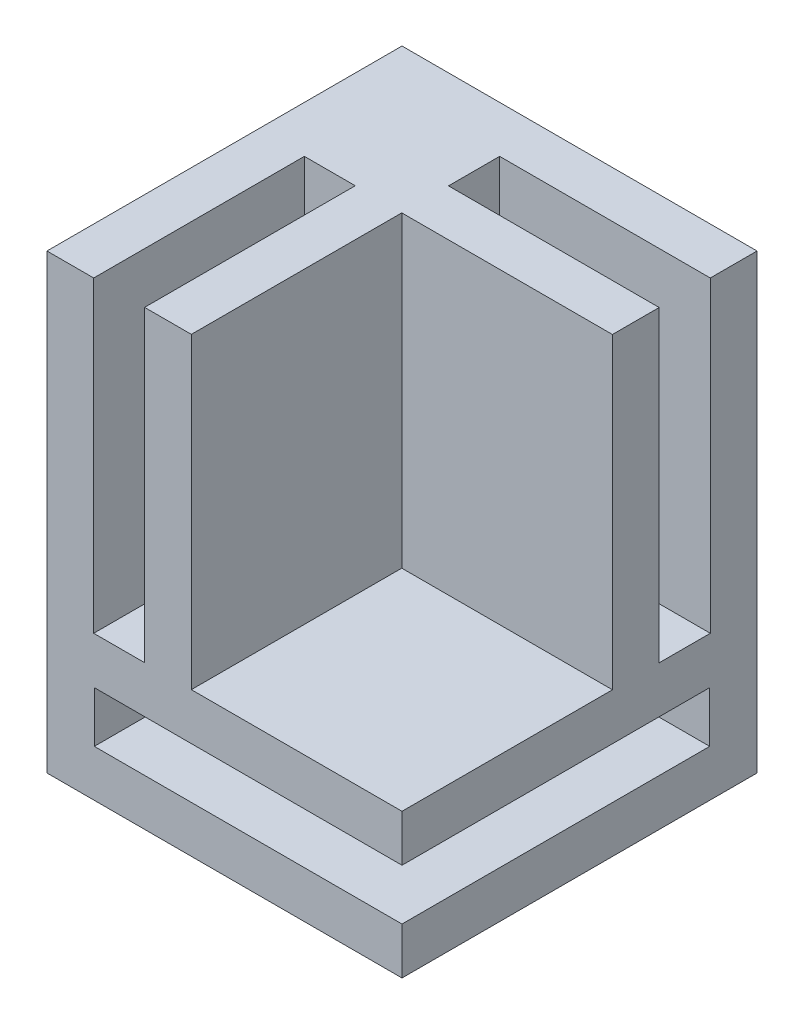
from build123d import *

# Parameters (mm, degrees)
SKETCH1_W           = 30
SKETCH1_H           = 12.2
BOSS_EXTRUDE1_DEPTH = 30
SKETCH2_W           = 26
SKETCH2_H           = 4.3
CUT_EXTRUDE1_DEPTH  = 26
SKETCH3_W           = 30
SKETCH3_H           = 30
BOSS_EXTRUDE2_DEPTH = 26
SKETCH4_W           = 17.8
SKETCH4_H           = 17.78
CUT_EXTRUDE2_DEPTH  = 26
SKETCH6_W           = 4.32
SKETCH6_H           = 26
CUT_EXTRUDE3_DEPTH  = 17.8
SKETCH9_W           = 4.3
SKETCH9_H           = 26
CUT_EXTRUDE4_DEPTH  = 17.8


with BuildPart() as part:
    # Sketch1 → Boss-Extrude1 (new body)
    with BuildSketch(Plane.XY):
        with Locations((-26.249929658, 18.197752809)):
            Rectangle(SKETCH1_W, SKETCH1_H)
    extrude(amount=BOSS_EXTRUDE1_DEPTH)

    # Sketch2 → Cut-Extrude1 (cut)
    with BuildSketch(Plane(origin=(-11.249929658, 0, 0), x_dir=(0, 0, -1), z_dir=(1, 0, 0))):
        with Locations((-17, 18.197752809)):
            Rectangle(SKETCH2_W, SKETCH2_H)
    extrude(amount=-CUT_EXTRUDE1_DEPTH, mode=Mode.SUBTRACT)

    # Sketch3 → Boss-Extrude2 (add)
    with BuildSketch(Plane(origin=(0, 24.297752809, 0), x_dir=(1, 0, 0), z_dir=(0, 1, 0))):
        with Locations((-26.249929658, -15)):
            Rectangle(SKETCH3_W, SKETCH3_H)
    extrude(amount=BOSS_EXTRUDE2_DEPTH)

    # Sketch4 → Cut-Extrude2 (cut)
    with BuildSketch(Plane(origin=(0, 50.297752809, 0), x_dir=(1, 0, 0), z_dir=(0, 1, 0))):
        with Locations((-20.149929658, -21.11)):
            Rectangle(SKETCH4_W, SKETCH4_H)
    extrude(amount=-CUT_EXTRUDE2_DEPTH, mode=Mode.SUBTRACT)

    # Sketch6 → Cut-Extrude3 (cut)
    with BuildSketch(Plane(origin=(-11.249929658, 0, 0), x_dir=(0, 0, -1), z_dir=(1, 0, 0))):
        with Locations((-6.11, 37.297752809)):
            Rectangle(SKETCH6_W, SKETCH6_H)
    extrude(amount=-CUT_EXTRUDE3_DEPTH, mode=Mode.SUBTRACT)

    # Sketch9 → Cut-Extrude4 (cut)
    with BuildSketch(Plane.XY.offset(30)):
        with Locations((-35.149929658, 37.297752809)):
            Rectangle(SKETCH9_W, SKETCH9_H)
    extrude(amount=-CUT_EXTRUDE4_DEPTH, mode=Mode.SUBTRACT)


solid = part.part
